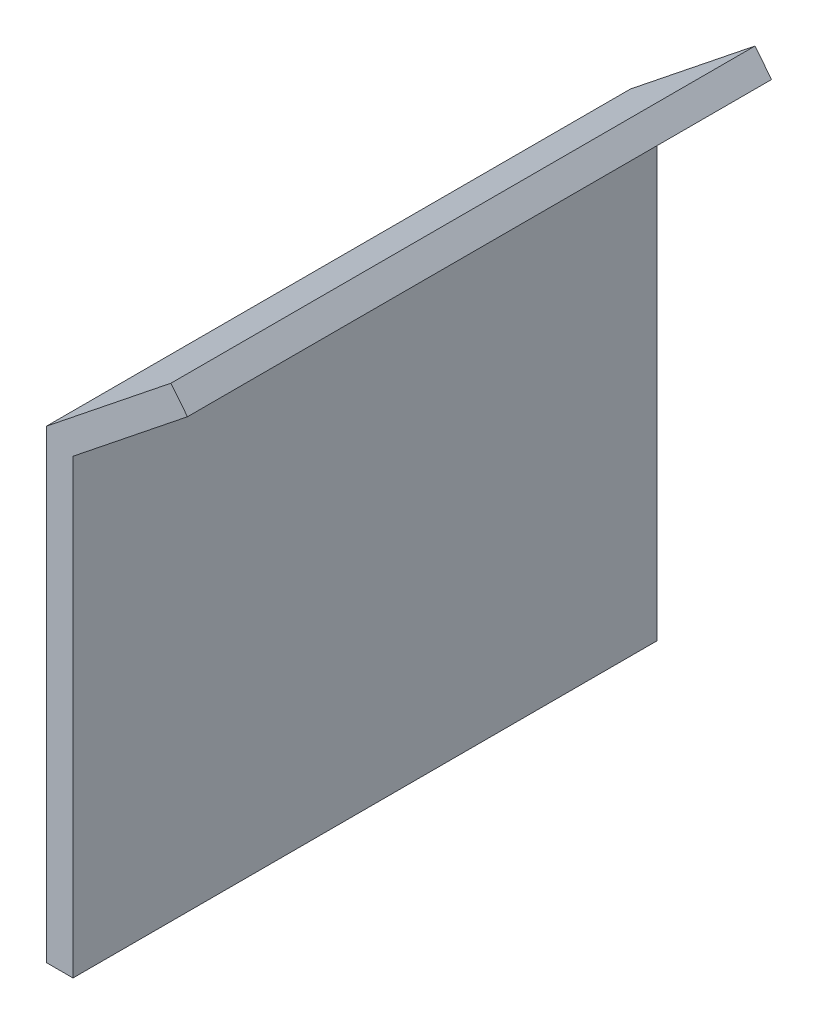
from build123d import *

# Parameters (mm, degrees)
BOSS_EXTRUDE1_DEPTH = 44


with BuildPart() as part:
    # Sketch1 → Boss-Extrude1 (new body)
    with BuildSketch(Plane.XY):
        Polygon((-95.841023878, 50.452952872), (-95.841023878, 84.490872654), (-87.217207217, 91.38039073), (-88.465543537, 92.942970787), (-97.841023878, 85.452952872), (-97.841023878, 50.452952872), align=None)
    extrude(amount=BOSS_EXTRUDE1_DEPTH)


solid = part.part
